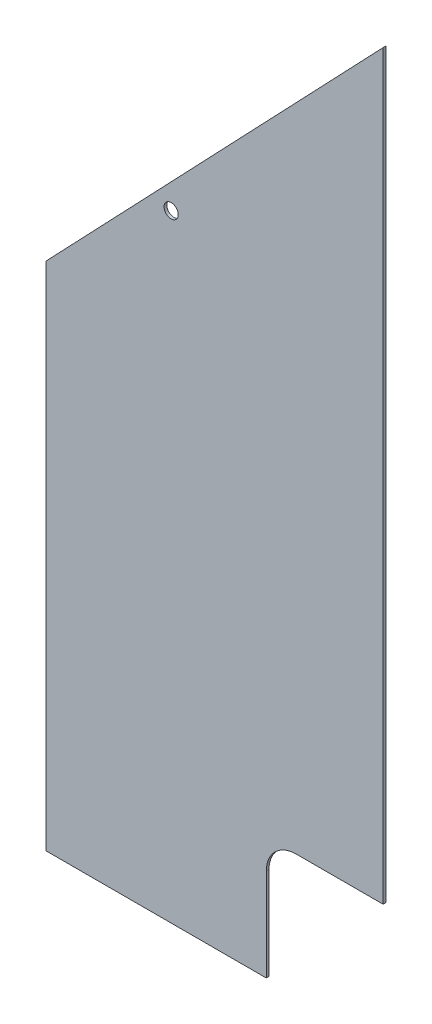
from build123d import *

# Parameters (mm, degrees)
BOSS_EXTRUDE1_DEPTH = 3.175
SKETCH5_R           = 8.255
CUT_EXTRUDE3_DEPTH  = 4.175
CUT_EXTRUDE4_DEPTH  = 4.175


with BuildPart() as part:
    # Sketch1 → Boss-Extrude1 (new body)
    with BuildSketch(Plane.XY):
        Polygon((0, 0), (-393.7, 0), (-393.7, 596.9), (0, 1009.65), align=None)
    extrude(amount=BOSS_EXTRUDE1_DEPTH)

    # Sketch5 → Cut-Extrude3 (cut, through all)
    with BuildSketch(Plane.XY.offset(3.175)):
        with Locations((-247.65, 720.725)):
            Circle(SKETCH5_R)
    extrude(amount=-CUT_EXTRUDE3_DEPTH, mode=Mode.SUBTRACT)

    # Sketch6 → Cut-Extrude4 (cut, through all)
    with BuildSketch(Plane.XY.offset(3.175)):
        with BuildLine():
            Line((0, 142.875), (-101.6, 142.875))
            ThreePointArc((-101.6, 142.875), (-126.295704333, 132.645704333), (-136.525, 107.95))
            Line((-136.525, 107.95), (-136.525, 0))
            Line((-136.525, 0), (0, 0))
            Line((0, 0), (0, 142.875))
        make_face()
    extrude(amount=-CUT_EXTRUDE4_DEPTH, mode=Mode.SUBTRACT)


solid = part.part
